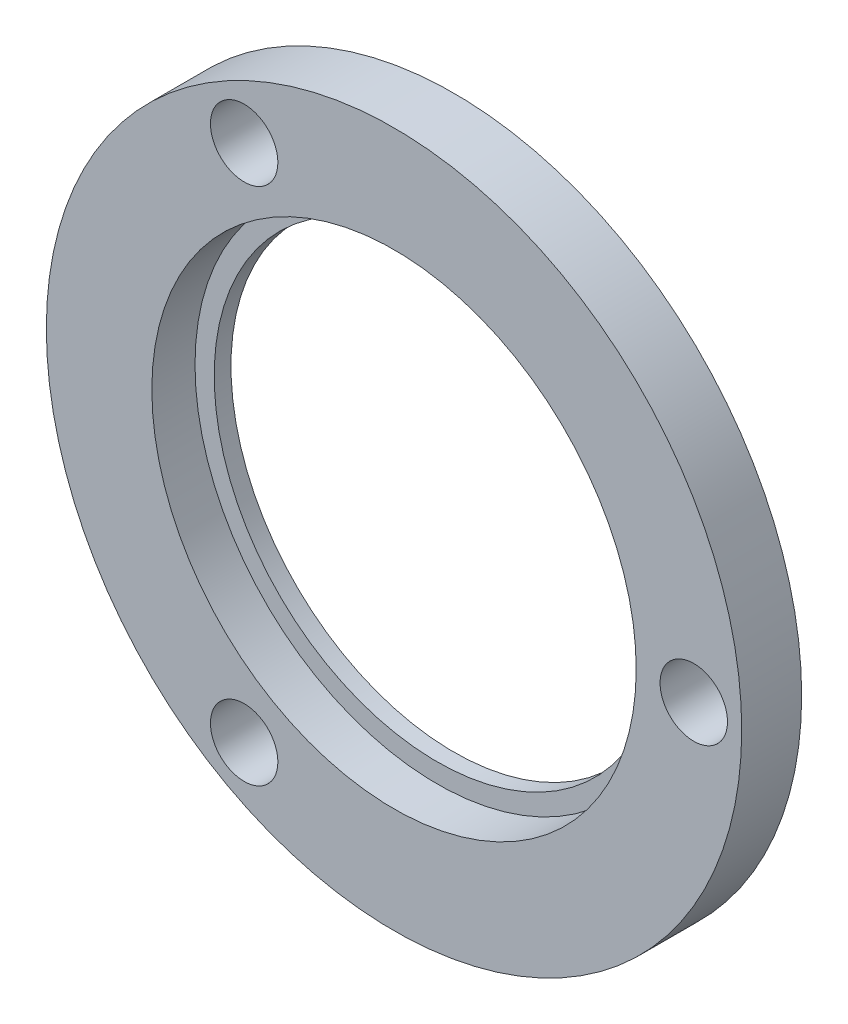
from build123d import *

# Parameters (mm, degrees)
SKETCH_R                = 36.83
SKETCH_R_2              = 23.622
BOSS_EXTRUDE1_DEPTH     = 6.35
SKETCH1_R               = 25.654
CUT_EXTRUDE1_DEPTH      = 4.572
F_1_4_CLEARANCE_HOLE1_D = 7.14248


with BuildPart() as part:
    # Sketch → Boss-Extrude1 (new body)
    with BuildSketch(Plane.XY):
        Circle(SKETCH_R)
        Circle(SKETCH_R_2, mode=Mode.SUBTRACT)
    extrude(amount=-BOSS_EXTRUDE1_DEPTH)

    # Sketch1 → Cut-Extrude1 (cut)
    with BuildSketch(Plane.XY):
        Circle(SKETCH1_R)
    extrude(amount=-CUT_EXTRUDE1_DEPTH, mode=Mode.SUBTRACT)

    # 1/4 Clearance Hole1 (through all)
    with Locations(Plane.XY):
        with Locations((31.75, 0), (-15.875, -27.49630657), (-15.875, 27.49630657)):
            Hole(F_1_4_CLEARANCE_HOLE1_D / 2)


solid = part.part
